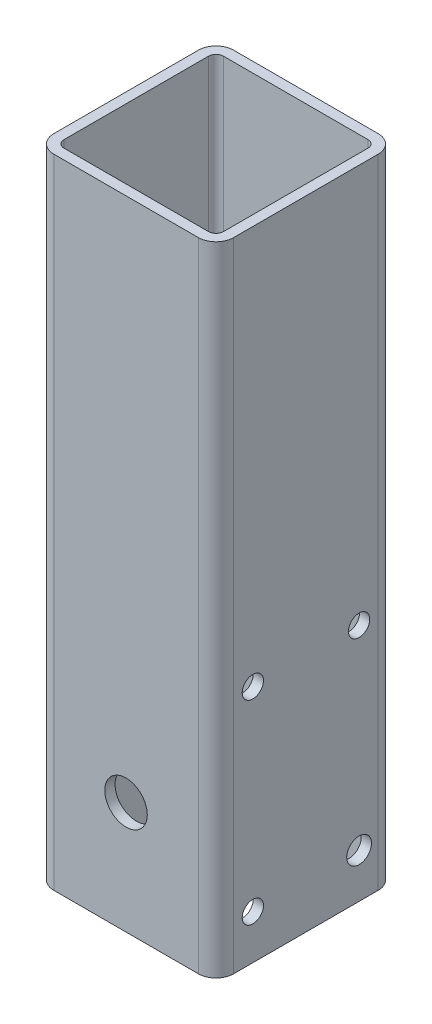
from build123d import *

# Parameters (mm, degrees)
BOSS_EXTRUDE1_DEPTH = 180
SKETCH3_R           = 3
SKETCH3_R_2         = 3.5
CUT_EXTRUDE1_DEPTH  = 95
SKETCH4_R           = 6
CUT_EXTRUDE2_DEPTH  = 95


with BuildPart() as part:
    # Sketch1 → Boss-Extrude1 (new body)
    with BuildSketch(Plane(origin=(0, 0, 0), x_dir=(1, 0, 0), z_dir=(0, 1, 0))):
        with BuildLine():
            Line((-20.4, 25.4), (20.4, 25.4))
            ThreePointArc((20.4, 25.4), (23.935533906, 23.935533906), (25.4, 20.4))
            Line((25.4, 20.4), (25.4, -20.4))
            ThreePointArc((25.4, -20.4), (23.935533906, -23.935533906), (20.4, -25.4))
            Line((20.4, -25.4), (-20.4, -25.4))
            ThreePointArc((-20.4, -25.4), (-23.935533906, -23.935533906), (-25.4, -20.4))
            Line((-25.4, -20.4), (-25.4, 20.4))
            ThreePointArc((-25.4, 20.4), (-23.935533906, 23.935533906), (-20.4, 25.4))
        make_face()
        with BuildLine():
            Line((-22.5, 20.4), (-22.5, -20.4))
            ThreePointArc((-22.5, -20.4), (-21.88492424, -21.88492424), (-20.4, -22.5))
            Line((-20.4, -22.5), (20.4, -22.5))
            ThreePointArc((20.4, -22.5), (21.88492424, -21.88492424), (22.5, -20.4))
            Line((22.5, -20.4), (22.5, 20.4))
            ThreePointArc((22.5, 20.4), (21.88492424, 21.88492424), (20.4, 22.5))
            Line((20.4, 22.5), (-20.4, 22.5))
            ThreePointArc((-20.4, 22.5), (-21.88492424, 21.88492424), (-22.5, 20.4))
        make_face(mode=Mode.SUBTRACT)
    extrude(amount=BOSS_EXTRUDE1_DEPTH)

    # Sketch3 → Cut-Extrude1 (cut)
    with BuildSketch(Plane.ZY.offset(25.4)):
        with Locations((-15, 67.5)):
            Circle(SKETCH3_R)
        with Locations((15, 67.5)):
            Circle(SKETCH3_R)
        with Locations((-15, 12.5)):
            Circle(SKETCH3_R_2)
        with Locations((15, 12.5)):
            Circle(SKETCH3_R)
    extrude(amount=-CUT_EXTRUDE1_DEPTH, mode=Mode.SUBTRACT)

    # Sketch4 → Cut-Extrude2 (cut)
    with BuildSketch(Plane.XY.offset(25.4)):
        with Locations((0, 31.67)):
            Circle(SKETCH4_R)
    extrude(amount=-CUT_EXTRUDE2_DEPTH, mode=Mode.SUBTRACT)


solid = part.part
